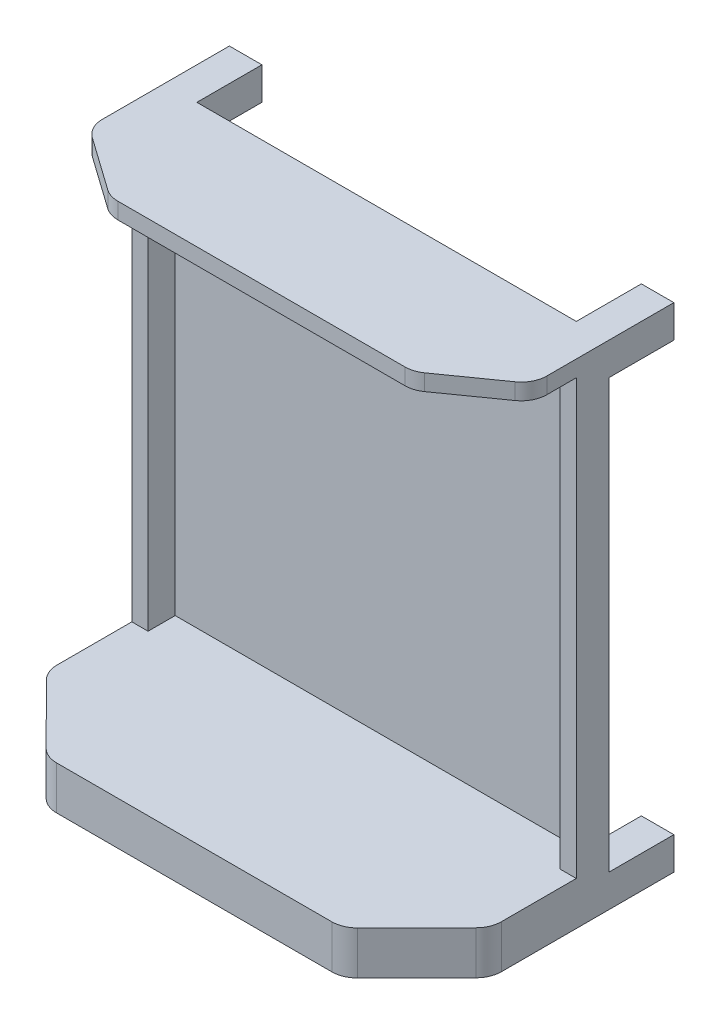
from build123d import *

# Parameters (mm, degrees)
SKETCH1_W           = 2082.8
SKETCH1_H           = 127
SKETCH1_H_2         = 2184.4
SKETCH1_W_2         = 1930.4
SKETCH1_H_3         = 2032
BOSS_EXTRUDE1_DEPTH = 127
BOSS_EXTRUDE2_DEPTH = 25.4
SKETCH3_W           = 2082.8
SKETCH3_H           = 203.2
BOSS_EXTRUDE3_DEPTH = 400
SKETCH4_W           = 2082.8
SKETCH4_H           = 76.2
BOSS_EXTRUDE4_DEPTH = 200
BOSS_EXTRUDE5_DEPTH = 203.2
BOSS_EXTRUDE6_DEPTH = 76.2
FILLET1_R           = 120
SKETCH7_W           = 152.4
SKETCH7_H           = 152.4
BOSS_EXTRUDE7_DEPTH = 304.8


with BuildPart() as part:
    # Sketch1 → Boss-Extrude1 (new body)
    with BuildSketch(Plane.XY):
        with Locations((965.2, -139.7)):
            Rectangle(SKETCH1_W, SKETCH1_H)
        with Locations((965.2, 1016)):
            Rectangle(SKETCH1_W, SKETCH1_H_2)
        with Locations((965.2, 1016)):
            Rectangle(SKETCH1_W_2, SKETCH1_H_3, mode=Mode.SUBTRACT)
    extrude(amount=BOSS_EXTRUDE1_DEPTH)

    # Sketch2 → Boss-Extrude2 (add)
    with BuildSketch(Plane(origin=(0, 0, 0), x_dir=(-1, 0, 0), z_dir=(0, 0, -1))):
        Polygon((76.2, 2108.2), (-2006.6, 2108.2), (-2006.6, -76.2), (-2006.6, -203.2), (76.2, -203.2), (76.2, -76.2), align=None)
    extrude(amount=BOSS_EXTRUDE2_DEPTH)

    # Sketch3 → Boss-Extrude3 (add)
    with BuildSketch(Plane.XY.offset(127)):
        with Locations((965.2, -101.6)):
            Rectangle(SKETCH3_W, SKETCH3_H)
    extrude(amount=BOSS_EXTRUDE3_DEPTH)

    # Sketch4 → Boss-Extrude4 (add)
    with BuildSketch(Plane.XY.offset(127)):
        with Locations((965.2, 2070.1)):
            Rectangle(SKETCH4_W, SKETCH4_H)
    extrude(amount=BOSS_EXTRUDE4_DEPTH)

    # Sketch5 → Boss-Extrude5 (add)
    with BuildSketch(Plane(origin=(0, 0, 0), x_dir=(1, 0, 0), z_dir=(0, 1, 0))):
        Polygon((2006.6, -527), (1659.609999688, -875.635603884), (270.790000312, -875.635603884), (-76.2, -527), align=None)
    extrude(amount=-BOSS_EXTRUDE5_DEPTH)

    # Sketch6 → Boss-Extrude6 (add)
    with BuildSketch(Plane(origin=(0, 2108.2, 0), x_dir=(1, 0, 0), z_dir=(0, 1, 0))):
        Polygon((965.2, -560.809930934), (965.2, -327), (-76.2, -327), (254.18871256, -560.809930934), align=None)
        Polygon((2006.6, -327), (965.2, -327), (965.2, -560.809930934), (1676.21128744, -560.809930934), align=None)
    extrude(amount=-BOSS_EXTRUDE6_DEPTH)

    # Fillet1
    fillet1_edges = [part.edges().sort_by_distance(p)[0] for p in [
        (2006.6, -101.6, 527),
        (-76.2, -101.6, 527),
        (-76.2, 2070.1, 327),
        (2006.6, 2070.1, 327),
        (270.790000312, -101.6, 875.635603884),
        (1659.609999688, -101.6, 875.635603884),
        (1676.21128744, 2070.1, 560.809930934),
        (254.18871256, 2070.1, 560.809930934),
    ]]
    fillet(fillet1_edges, radius=FILLET1_R)

    # Sketch7 → Boss-Extrude7 (add)
    with BuildSketch(Plane(origin=(0, 0, -25.4), x_dir=(-1, 0, 0), z_dir=(0, 0, -1))):
        with Locations((0, 2032)):
            Rectangle(SKETCH7_W, SKETCH7_H)
        with Locations((-1930.4, 2032)):
            Rectangle(SKETCH7_W, SKETCH7_H)
        with Locations((0, -127)):
            Rectangle(SKETCH7_W, SKETCH7_H)
        with Locations((-1930.4, -127)):
            Rectangle(SKETCH7_W, SKETCH7_H)
    extrude(amount=BOSS_EXTRUDE7_DEPTH)


solid = part.part
